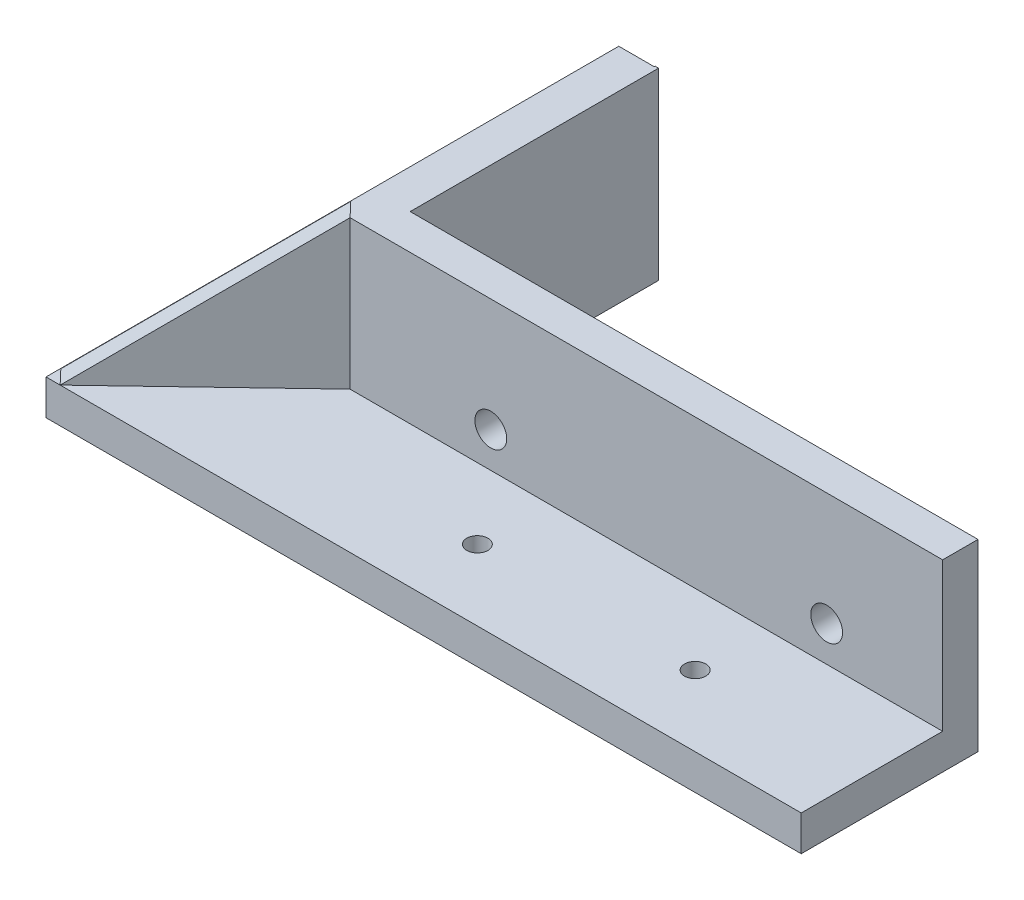
from build123d import *

# Parameters (mm, degrees)
CROQUIS1_W              = 80.8
CROQUIS1_H              = 25
CROQUIS1_R              = 1.5
SALIENTE_EXTRUIR1_DEPTH = 5
CROQUIS1_3_W            = 80.8
CROQUIS1_3_H            = 5
SALIENTE_EXTRUIR2_DEPTH = 26
CROQUIS1_4_W            = 26
CROQUIS1_4_H            = 60
CROQUIS1_4_R            = 1.5
SALIENTE_EXTRUIR3_DEPTH = 5
CROQUIS1_5_W            = 5
CROQUIS1_5_H            = 40
SALIENTE_EXTRUIR4_DEPTH = 26
CROQUIS3_R              = 2.25
CORTAR_EXTRUIR1_DEPTH   = 26
SALIENTE_EXTRUIR5_DEPTH = 21
CORTAR_EXTRUIR2_DEPTH   = 21
CROQUIS7_W              = 36.882036787
CROQUIS7_H              = 40.226112096
CORTAR_EXTRUIR3_DEPTH   = 90
CROQUIS8_W              = 35.258342774
CROQUIS8_H              = 26
SALIENTE_EXTRUIR6_DEPTH = 0.5


with BuildPart() as part:
    # Croquis1 → Saliente-Extruir1 (new body)
    with BuildSketch(Plane(origin=(0, 0, 0), x_dir=(1, 0, 0), z_dir=(0, 1, 0))):
        with Locations((0, -10)):
            Rectangle(CROQUIS1_W, CROQUIS1_H)
        with Locations((15.4, -12.5)):
            Circle(CROQUIS1_R, mode=Mode.SUBTRACT)
        with Locations((-15.4, -12.5)):
            Circle(CROQUIS1_R, mode=Mode.SUBTRACT)
    extrude(amount=SALIENTE_EXTRUIR1_DEPTH)

    # Croquis1_3 → Saliente-Extruir2 (add)
    with BuildSketch(Plane(origin=(0, 0, 0), x_dir=(1, 0, 0), z_dir=(0, 1, 0))):
        Rectangle(CROQUIS1_3_W, CROQUIS1_3_H)
    extrude(amount=SALIENTE_EXTRUIR2_DEPTH)

    # Croquis1_4 → Saliente-Extruir3 (add)
    # profile 1 of 2: a face of its own
    with BuildSketch(Plane(origin=(0, 0, 0), x_dir=(1, 0, 0), z_dir=(0, 1, 0))):
        with Locations((-53.4, 7.5)):
            Rectangle(CROQUIS1_4_W, CROQUIS1_4_H)
        with Locations((-55.4, 12.5)):
            Circle(CROQUIS1_4_R, mode=Mode.SUBTRACT)
    # profile 2 of 2: a face of its own
    with BuildSketch(Plane(origin=(0, 0, 0), x_dir=(1, 0, 0), z_dir=(0, 1, 0))):
        with Locations((53.4, 7.5)):
            Rectangle(CROQUIS1_4_W, CROQUIS1_4_H)
        with Locations((55.4, 12.5)):
            Circle(CROQUIS1_4_R, mode=Mode.SUBTRACT)
    extrude(amount=SALIENTE_EXTRUIR3_DEPTH)

    # Croquis1_5 → Saliente-Extruir4 (add)
    with BuildSketch(Plane(origin=(0, 0, 0), x_dir=(1, 0, 0), z_dir=(0, 1, 0))):
        with Locations((-42.9, 17.5)):
            Rectangle(CROQUIS1_5_W, CROQUIS1_5_H)
        with Locations((42.9, 17.5)):
            Rectangle(CROQUIS1_5_W, CROQUIS1_5_H)
    extrude(amount=SALIENTE_EXTRUIR4_DEPTH)

    # Croquis3 → Cortar-Extruir1 (cut)
    with BuildSketch(Plane.XY.offset(2.5)):
        with Locations((-23.5, 10)):
            Circle(CROQUIS3_R)
        with Locations((24, 10)):
            Circle(CROQUIS3_R)
    extrude(amount=-CORTAR_EXTRUIR1_DEPTH, mode=Mode.SUBTRACT)

    # Croquis4 → Saliente-Extruir5 (add)
    with BuildSketch(Plane(origin=(0, 5, 0), x_dir=(1, 0, 0), z_dir=(0, 1, 0))):
        Polygon((-45.4, -0.5), (-45.4, -2.5), (-43.4, -2.5), (-64.4, -22.5), (-66.4, -22.5), (-66.4, -20.5), align=None)
    saliente_extruir5 = extrude(amount=SALIENTE_EXTRUIR5_DEPTH)

    # Croquis5 → Cortar-Extruir2 (cut)
    with BuildSketch(Plane(origin=(-19.393579073, 0, -20.363258026), x_dir=(0.7241379310344827, 0, -0.6896551724137933), z_dir=(0.6896551724137933, 0, 0.7241379310344827))):
        Polygon((-62.151724138, 5), (-33.151724138, 26), (-26.486949689, 30.82621598), (-82.759555013, 33.403814281), (-84.060607683, 5), align=None)
    cortar_extruir2 = extrude(amount=-CORTAR_EXTRUIR2_DEPTH, mode=Mode.SUBTRACT)

    # Simetría1: Saliente-Extruir5 across plane
    add(saliente_extruir5.mirror(Plane(origin=(0, 0, 0), x_dir=(0, 0, 1), z_dir=(1, 0, 0))))

    # Simetría2: Cortar-Extruir2 across plane
    add(cortar_extruir2.mirror(Plane(origin=(0, 0, 0), x_dir=(0, 0, 1), z_dir=(1, 0, 0))), mode=Mode.SUBTRACT)

    # Croquis7 → Cortar-Extruir3 (cut)
    with BuildSketch(Plane(origin=(0, 0, -37.5), x_dir=(-1, 0, 0), z_dir=(0, 0, -1))):
        with Locations((-58.841018394, 20.113056048)):
            Rectangle(CROQUIS7_W, CROQUIS7_H)
    extrude(amount=-CORTAR_EXTRUIR3_DEPTH, mode=Mode.SUBTRACT)

    # Croquis8 → Saliente-Extruir6 (add)
    with BuildSketch(Plane(origin=(-40.4, 0, 0), x_dir=(0, 0, -1), z_dir=(1, 0, 0))):
        with Locations((20, 13)):
            Rectangle(CROQUIS8_W, CROQUIS8_H)
    extrude(amount=SALIENTE_EXTRUIR6_DEPTH)


solid = part.part
